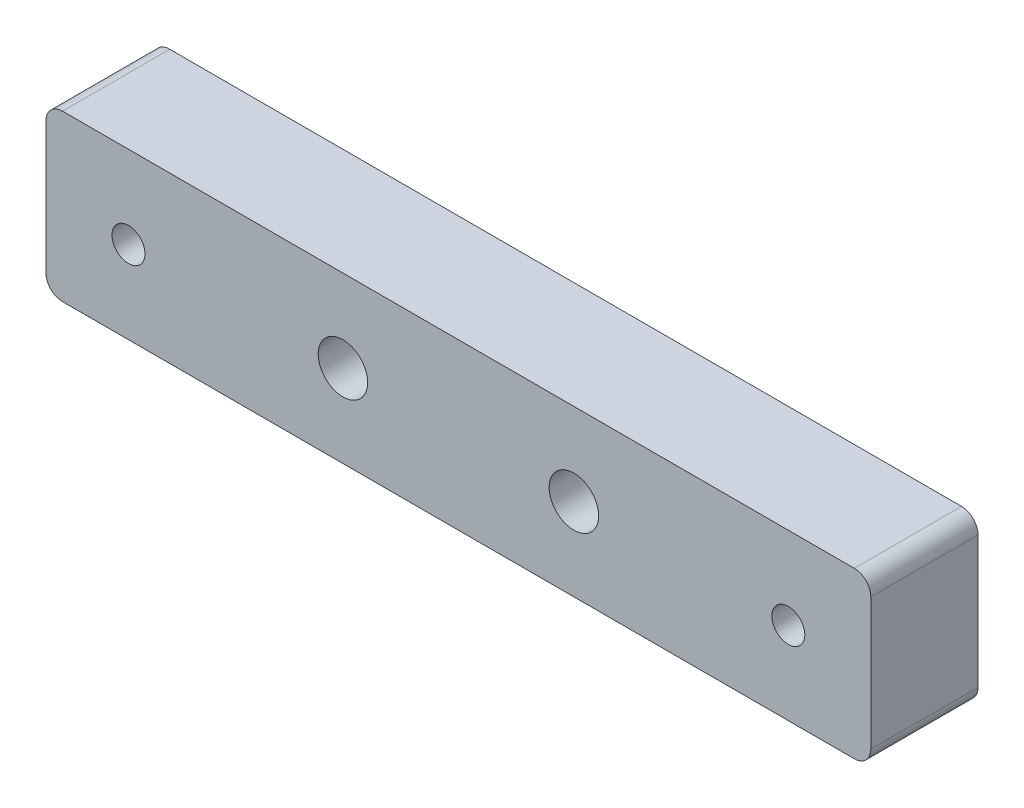
from build123d import *

# Parameters (mm, degrees)
SKETCH1_W           = 100
SKETCH1_H           = 20
BOSS_EXTRUDE1_DEPTH = 13
SKETCH2_R           = 3
SKETCH2_R_2         = 2
CUT_EXTRUDE1_DEPTH  = 13
CUT_EXTRUDE2_DEPTH  = 13


with BuildPart() as part:
    # Sketch1 → Boss-Extrude1 (new body)
    with BuildSketch(Plane.XY):
        with Locations((50, 10)):
            Rectangle(SKETCH1_W, SKETCH1_H)
    extrude(amount=BOSS_EXTRUDE1_DEPTH)

    # Sketch2 → Cut-Extrude1 (cut)
    with BuildSketch(Plane.XY.offset(13)):
        with Locations((64, 10)):
            Circle(SKETCH2_R)
        with Locations((36, 10)):
            Circle(SKETCH2_R)
        with Locations((10, 10)):
            Circle(SKETCH2_R_2)
        with Locations((90, 10)):
            Circle(SKETCH2_R_2)
    extrude(amount=-CUT_EXTRUDE1_DEPTH, mode=Mode.SUBTRACT)

    # Sketch3 → Cut-Extrude2 (cut)
    with BuildSketch(Plane.XY.offset(13)):
        with BuildLine():
            ThreePointArc((98, 20), (99.414213562, 19.414213562), (100, 18))
            Line((100, 18), (100, 20))
            Line((100, 20), (98, 20))
        make_face()
        with BuildLine():
            ThreePointArc((100, 2), (99.414213562, 0.585786438), (98, 0))
            Line((98, 0), (100, 0))
            Line((100, 0), (100, 2))
        make_face()
        with BuildLine():
            Line((0, 0), (2, 0))
            ThreePointArc((2, 0), (0.585786438, 0.585786438), (0, 2))
            Line((0, 2), (0, 0))
        make_face()
        with BuildLine():
            Line((0, 20), (0, 18))
            ThreePointArc((0, 18), (0.585786438, 19.414213562), (2, 20))
            Line((2, 20), (0, 20))
        make_face()
    extrude(amount=-CUT_EXTRUDE2_DEPTH, mode=Mode.SUBTRACT)


solid = part.part
